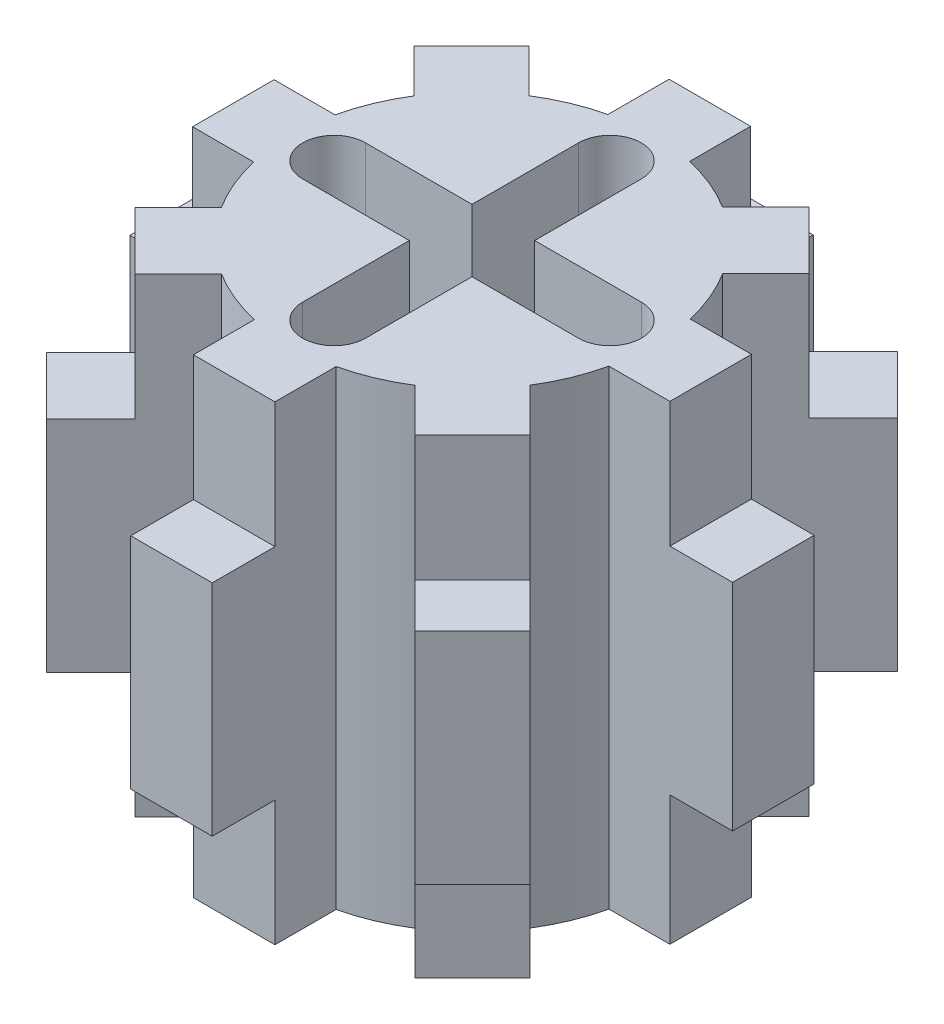
from build123d import *

# Parameters (mm, degrees)
SKETCH1_R            = 2.9
BOSS_EXTRUDE1_DEPTH  = 7.5
SKETCH2_W            = 1
SKETCH2_H            = 1
CUT_EXTRUDE1_DEPTH   = 7.5
SKETCH8_W            = 1.3
SKETCH8_H            = 7.5
BOSS_EXTRUDE4_DEPTH  = 1
CIRPATTERN3_COUNT    = 8
SKETCH10_W           = 1.3
SKETCH10_H           = 3.5
BOSS_EXTRUDE6_DEPTH  = 1
SKETCH11_W           = 1.3
SKETCH11_H           = 3.5
BOSS_EXTRUDE7_DEPTH  = 1
SKETCH12_W           = 1.3
SKETCH12_H           = 3.5
BOSS_EXTRUDE8_DEPTH  = 1
SKETCH14_W           = 1.3
SKETCH14_H           = 3.5
BOSS_EXTRUDE9_DEPTH  = 1
SKETCH15_W           = 1.3
SKETCH15_H           = 3.5
BOSS_EXTRUDE10_DEPTH = 1
SKETCH16_W           = 1.3
SKETCH16_H           = 3.5
BOSS_EXTRUDE11_DEPTH = 1
SKETCH17_W           = 1.3
SKETCH17_H           = 3.43512081
BOSS_EXTRUDE12_DEPTH = 1
SKETCH18_W           = 1.3
SKETCH18_H           = 3.5
BOSS_EXTRUDE13_DEPTH = 1


with BuildPart() as part:
    # Sketch1 → Boss-Extrude1 (new body)
    with BuildSketch(Plane(origin=(0, 0, 0), x_dir=(1, 0, 0), z_dir=(0, 1, 0))):
        Circle(SKETCH1_R)
    extrude(amount=BOSS_EXTRUDE1_DEPTH)

    # Sketch2 → Cut-Extrude1 (cut)
    with BuildSketch(Plane.XZ):
        with BuildLine():
            Line((0.5, 0.5), (0.5, 2.2))
            ThreePointArc((0.5, 2.2), (0, 2.7), (-0.5, 2.2))
            Line((-0.5, 2.2), (-0.5, 0.5))
            Line((-0.5, 0.5), (0.5, 0.5))
        make_face()
        Rectangle(SKETCH2_W, SKETCH2_H)
        with BuildLine():
            Line((0.5, -2.2), (0.5, -0.5))
            Line((0.5, -0.5), (-0.5, -0.5))
            Line((-0.5, -0.5), (-0.5, -2.2))
            ThreePointArc((-0.5, -2.2), (0, -2.7), (0.5, -2.2))
        make_face()
        with BuildLine():
            Line((2.2, 0.5), (0.5, 0.5))
            Line((0.5, 0.5), (0.5, -0.5))
            Line((0.5, -0.5), (2.2, -0.5))
            ThreePointArc((2.2, -0.5), (2.7, 0), (2.2, 0.5))
        make_face()
        with BuildLine():
            Line((-0.5, -0.5), (-0.5, 0.5))
            Line((-0.5, 0.5), (-2.2, 0.5))
            ThreePointArc((-2.2, 0.5), (-2.7, 0), (-2.2, -0.5))
            Line((-2.2, -0.5), (-0.5, -0.5))
        make_face()
    extrude(amount=-CUT_EXTRUDE1_DEPTH, mode=Mode.SUBTRACT)

    # Sketch8 → Boss-Extrude4 (add)
    with BuildSketch(Plane(origin=(2.8, 0, 0), x_dir=(0, 0, -1), z_dir=(1, 0, 0))):
        with Locations((0.006709133, 3.75)):
            Rectangle(SKETCH8_W, SKETCH8_H)
    boss_extrude4 = extrude(amount=BOSS_EXTRUDE4_DEPTH)

    # CirPattern3: Boss-Extrude4 ×8 about axis
    cirpattern3_axis = Axis((0, 0, 0), (0, 1, 0))
    for i in range(1, CIRPATTERN3_COUNT):
        add(boss_extrude4.rotate(cirpattern3_axis, i * 360 / CIRPATTERN3_COUNT))

    # Sketch10 → Boss-Extrude6 (add)
    with BuildSketch(Plane(origin=(0, 0, -3.8), x_dir=(-1, 0, 0), z_dir=(0, 0, -1))):
        with Locations((0.006709133, 3.75)):
            Rectangle(SKETCH10_W, SKETCH10_H)
    extrude(amount=BOSS_EXTRUDE6_DEPTH)

    # Sketch11 → Boss-Extrude7 (add)
    with BuildSketch(Plane(origin=(-2.687005769, 0, -2.687005769), x_dir=(-0.707106781, 0, 0.707106781), z_dir=(-0.707106781, 0, -0.707106781))):
        with Locations((0.006709133, 3.75)):
            Rectangle(SKETCH11_W, SKETCH11_H)
    extrude(amount=BOSS_EXTRUDE7_DEPTH)

    # Sketch12 → Boss-Extrude8 (add)
    with BuildSketch(Plane.ZY.offset(3.8)):
        with Locations((0.006709133, 3.75)):
            Rectangle(SKETCH12_W, SKETCH12_H)
    extrude(amount=BOSS_EXTRUDE8_DEPTH)

    # Sketch14 → Boss-Extrude9 (add)
    with BuildSketch(Plane(origin=(-2.687005769, 0, 2.687005769), x_dir=(0.707106781, 0, 0.707106781), z_dir=(-0.707106781, 0, 0.707106781))):
        with Locations((0.006709133, 3.75)):
            Rectangle(SKETCH14_W, SKETCH14_H)
    extrude(amount=BOSS_EXTRUDE9_DEPTH)

    # Sketch15 → Boss-Extrude10 (add)
    with BuildSketch(Plane.XY.offset(3.8)):
        with Locations((0.006709133, 3.75)):
            Rectangle(SKETCH15_W, SKETCH15_H)
    extrude(amount=BOSS_EXTRUDE10_DEPTH)

    # Sketch16 → Boss-Extrude11 (add)
    with BuildSketch(Plane(origin=(2.687005769, 0, 2.687005769), x_dir=(0.707106781, 0, -0.707106781), z_dir=(0.707106781, 0, 0.707106781))):
        with Locations((0.006709133, 3.75)):
            Rectangle(SKETCH16_W, SKETCH16_H)
    extrude(amount=BOSS_EXTRUDE11_DEPTH)

    # Sketch17 → Boss-Extrude12 (add)
    with BuildSketch(Plane(origin=(3.8, 0, 0), x_dir=(0, 0, -1), z_dir=(1, 0, 0))):
        with Locations((0.006709133, 3.782439595)):
            Rectangle(SKETCH17_W, SKETCH17_H)
    extrude(amount=BOSS_EXTRUDE12_DEPTH)

    # Sketch18 → Boss-Extrude13 (add)
    with BuildSketch(Plane(origin=(2.687005769, 0, -2.687005769), x_dir=(-0.707106781, 0, -0.707106781), z_dir=(0.707106781, 0, -0.707106781))):
        with Locations((0.006709133, 3.75)):
            Rectangle(SKETCH18_W, SKETCH18_H)
    extrude(amount=BOSS_EXTRUDE13_DEPTH)


solid = part.part
